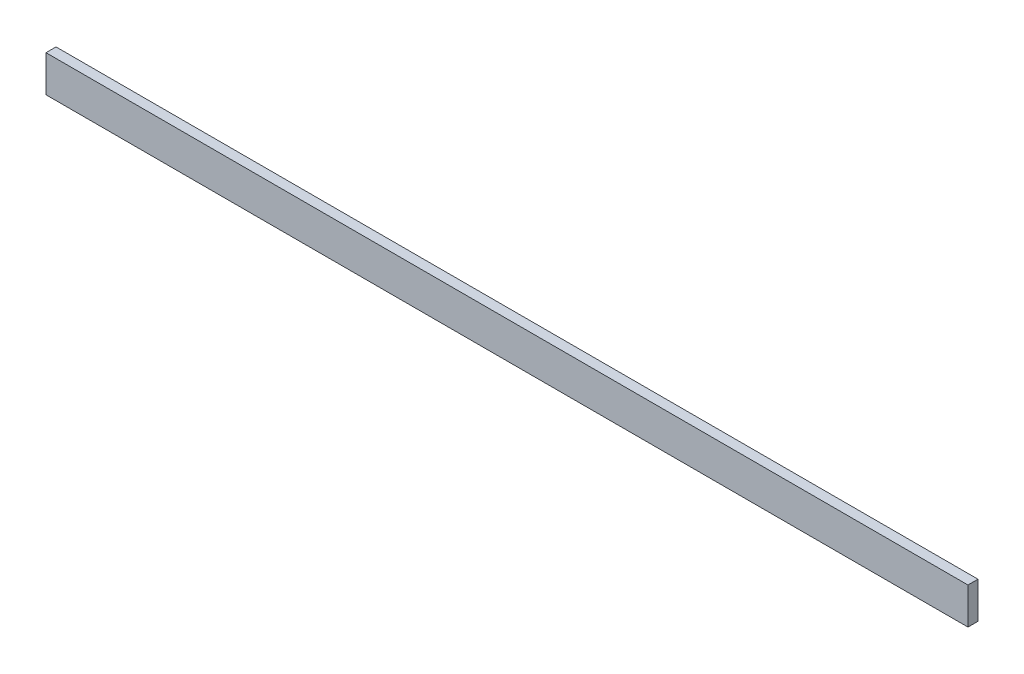
from build123d import *

# Parameters (mm, degrees)
ESQUISSE1_W      = 2022
ESQUISSE1_H      = 80
EXTRUSION1_DEPTH = 22


with BuildPart() as part:
    # Esquisse1 → Extrusion1 (new body)
    with BuildSketch(Plane.XY):
        with Locations((1011, 40)):
            Rectangle(ESQUISSE1_W, ESQUISSE1_H)
    extrude(amount=EXTRUSION1_DEPTH)


solid = part.part
